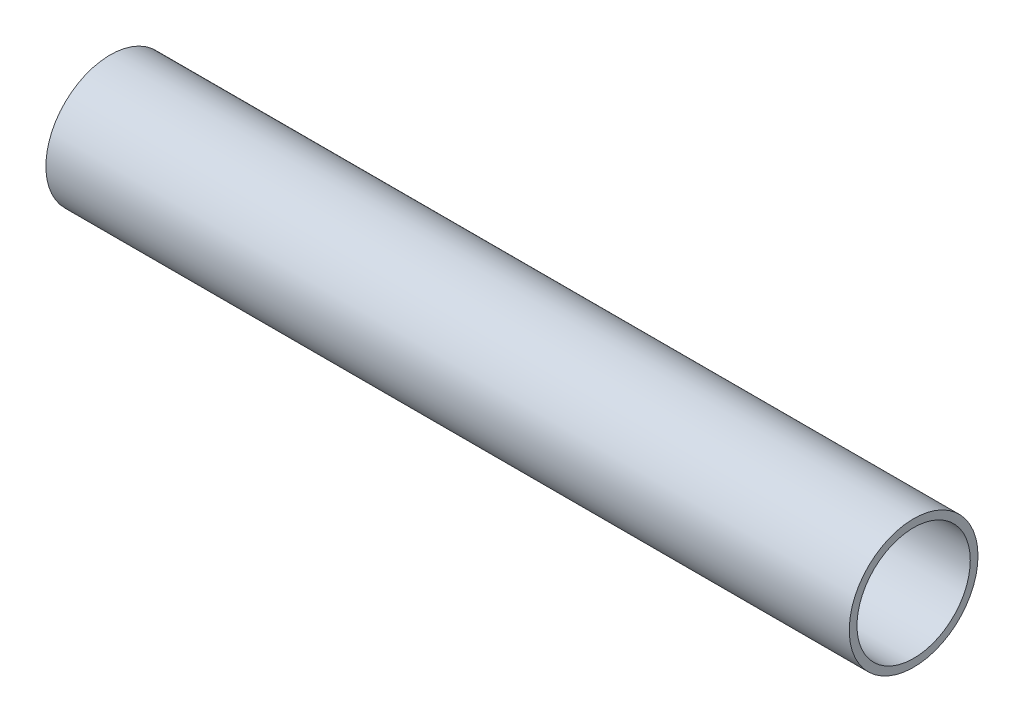
from build123d import *

# Parameters (mm, degrees)
ESQUISSE1_R        = 12.5
ESQUISSE1_R_2      = 11
BOSS_EXTRU_1_DEPTH = 156


with BuildPart() as part:
    # Esquisse1 → Boss.-Extru.1 (new body)
    with BuildSketch(Plane(origin=(0, 0, 0), x_dir=(0, 0, -1), z_dir=(1, 0, 0))):
        Circle(ESQUISSE1_R)
        Circle(ESQUISSE1_R_2, mode=Mode.SUBTRACT)
    extrude(amount=BOSS_EXTRU_1_DEPTH)


solid = part.part
